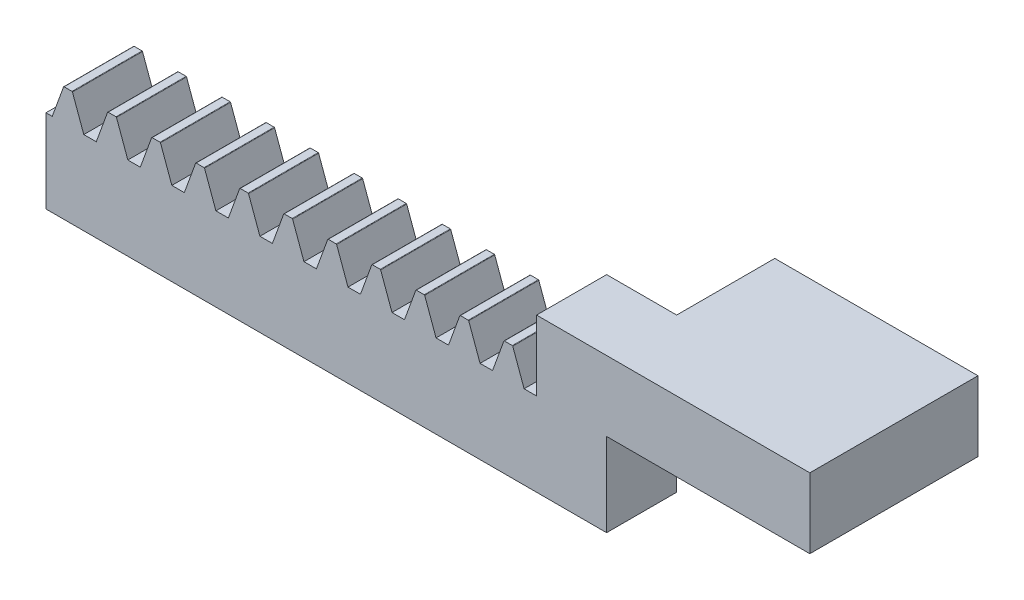
from build123d import *

# Parameters (mm, degrees)
BLANKSKE_W          = 40
BLANKSKE_H          = 8.2
BLANK_DEPTH         = 5
TOOTHCUTILL_DEPTH   = 42.136844799
TOOTHCUTSIM_DEPTH   = 42.136844799
TEETHCUTS_COUNT     = 13
TEETHCUTS_PITCH     = 3.14159265
SKETCH1_W           = 4.99804548
SKETCH1_H           = 2.25
BOSS_EXTRUDE1_DEPTH = 5
SKETCH4_W           = 12
SKETCH4_H           = 2.25
BOSS_EXTRUDE4_DEPTH = 14.5
BOSS_EXTRUDE5_DEPTH = 2.75


with BuildPart() as part:
    # BlankSke → Blank (new body)
    with BuildSketch(Plane.XY):
        with Locations((20, 4.1)):
            Rectangle(BLANKSKE_W, BLANKSKE_H)
    extrude(amount=-BLANK_DEPTH)

    # TooCutSkeIll → ToothCutIll (cut, through all)
    with BuildSketch(Plane.XY):
        with BuildLine():
            Line((-1.253788993, 8.173680806), (-0.504546125, 6.115152944))
            ThreePointArc((-0.504546125, 6.115152944), (-0.412650963, 5.995392837), (-0.268683278, 5.95))
            Line((-0.268683278, 5.95), (0.268683278, 5.95))
            ThreePointArc((0.268683278, 5.95), (0.412650963, 5.995392837), (0.504546125, 6.115152944))
            Line((0.504546125, 6.115152944), (1.253788993, 8.173680806))
            ThreePointArc((1.253788993, 8.173680806), (1.268433641, 8.192766082), (1.291376698, 8.2))
            Line((1.291376698, 8.2), (1.291376698, 8.2254))
            Line((1.291376698, 8.2254), (-1.291376698, 8.2254))
            Line((-1.291376698, 8.2254), (-1.291376698, 8.2))
            ThreePointArc((-1.291376698, 8.2), (-1.268433641, 8.192766082), (-1.253788993, 8.173680806))
        make_face()
    toothcutill = extrude(amount=-TOOTHCUTILL_DEPTH, mode=Mode.SUBTRACT)

    # TooCutSkeSim → ToothCutSim (cut, through all)
    with BuildSketch(Plane.XY):
        Polygon((0.44443537, 5.95), (-0.44443537, 5.95), (-1.272613241, 8.2254), (1.272613241, 8.2254), align=None)
    toothcutsim = extrude(amount=-TOOTHCUTSIM_DEPTH, mode=Mode.SUBTRACT)

    # TeethCuts: ToothCutIll, ToothCutSim ×13
    with Locations(*[(i * TEETHCUTS_PITCH, 0, 0) for i in range(1, TEETHCUTS_COUNT)]):
        add(toothcutill, mode=Mode.SUBTRACT)
        add(toothcutsim, mode=Mode.SUBTRACT)

    # Sketch1 → Boss-Extrude1 (add)
    with BuildSketch(Plane.XY):
        with Locations((37.50097726, 7.075)):
            Rectangle(SKETCH1_W, SKETCH1_H)
    extrude(amount=-BOSS_EXTRUDE1_DEPTH)

    # Sketch4 → Boss-Extrude4 (add)
    with BuildSketch(Plane(origin=(40, 0, 0), x_dir=(0, 0, -1), z_dir=(1, 0, 0))):
        with Locations((6, 7.075)):
            Rectangle(SKETCH4_W, SKETCH4_H)
    extrude(amount=BOSS_EXTRUDE4_DEPTH)

    # Sketch6 → Boss-Extrude5 (add)
    with BuildSketch(Plane(origin=(0, 8.2, 0), x_dir=(1, 0, 0), z_dir=(0, 1, 0))):
        Polygon((35.00195452, 5), (35.00195452, 0), (54.5, 0), (54.5, 12), (40, 12), (40, 5), align=None)
    extrude(amount=BOSS_EXTRUDE5_DEPTH)


solid = part.part
